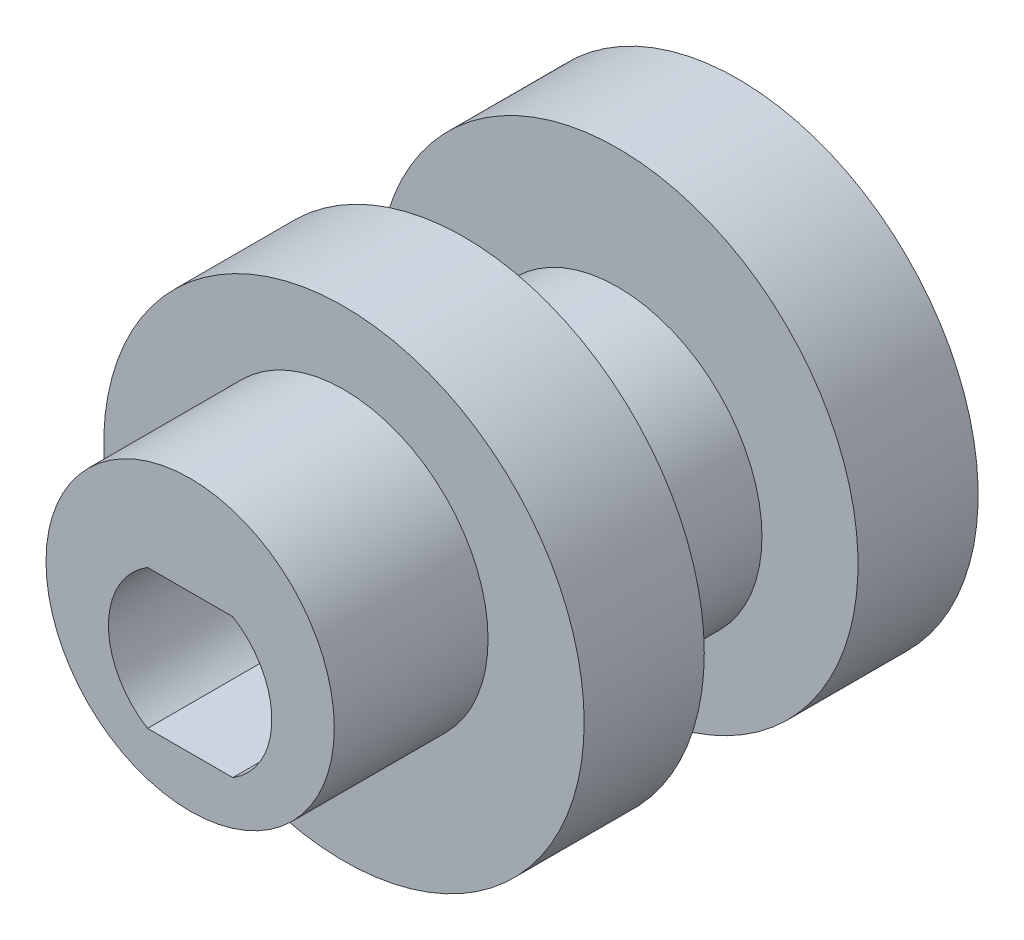
from build123d import *

# Parameters (mm, degrees)
SKETCH6_R               = 10
BOSS_EXTRUDE4_DEPTH     = 2.5
SKETCH7_R               = 6
BOSS_EXTRUDE5_DEPTH     = 6.4
SKETCH8_R               = 6
BOSS_EXTRUDE6_DEPTH     = 6.4
SKETCH12_R              = 10
BOSS_EXTRUDE8_DEPTH     = 5
CUT_EXTRUDE1_DEPTH      = 7.4
CUT_EXTRUDE1_DEPTH_BACK = 17.4


with BuildPart() as part:
    # Sketch6 → Boss-Extrude4 (new body, symmetric)
    with BuildSketch(Plane.XY):
        Circle(SKETCH6_R)
    extrude(amount=BOSS_EXTRUDE4_DEPTH, both=True)

    # Sketch7 → Boss-Extrude5 (add)
    with BuildSketch(Plane.XY.offset(2.5)):
        with Locations((0, 1)):
            Circle(SKETCH7_R)
    extrude(amount=BOSS_EXTRUDE5_DEPTH)

    # Sketch8 → Boss-Extrude6 (add)
    with BuildSketch(Plane(origin=(0, 0, -2.5), x_dir=(-1, 0, 0), z_dir=(0, 0, -1))):
        with Locations((0, -1)):
            Circle(SKETCH8_R)
    extrude(amount=BOSS_EXTRUDE6_DEPTH)

    # Sketch12 → Boss-Extrude8 (add)
    with BuildSketch(Plane(origin=(0, 0, -8.9), x_dir=(-1, 0, 0), z_dir=(0, 0, -1))):
        Circle(SKETCH12_R)
    extrude(amount=BOSS_EXTRUDE8_DEPTH)

    # Sketch11 → Cut-Extrude1 (cut, two sides)
    with BuildSketch(Plane.XY.offset(2.5)) as cut_extrude1_sk:
        with BuildLine():
            Line((-1.774823935, -2.9), (1.774823935, -2.9))
            ThreePointArc((1.774823935, -2.9), (3.4, 0), (1.774823935, 2.9))
            Line((1.774823935, 2.9), (-1.774823935, 2.9))
            ThreePointArc((-1.774823935, 2.9), (-3.4, 0), (-1.774823935, -2.9))
        make_face()
    extrude(amount=CUT_EXTRUDE1_DEPTH, mode=Mode.SUBTRACT)
    extrude(cut_extrude1_sk.sketch, amount=-CUT_EXTRUDE1_DEPTH_BACK, mode=Mode.SUBTRACT)


solid = part.part
